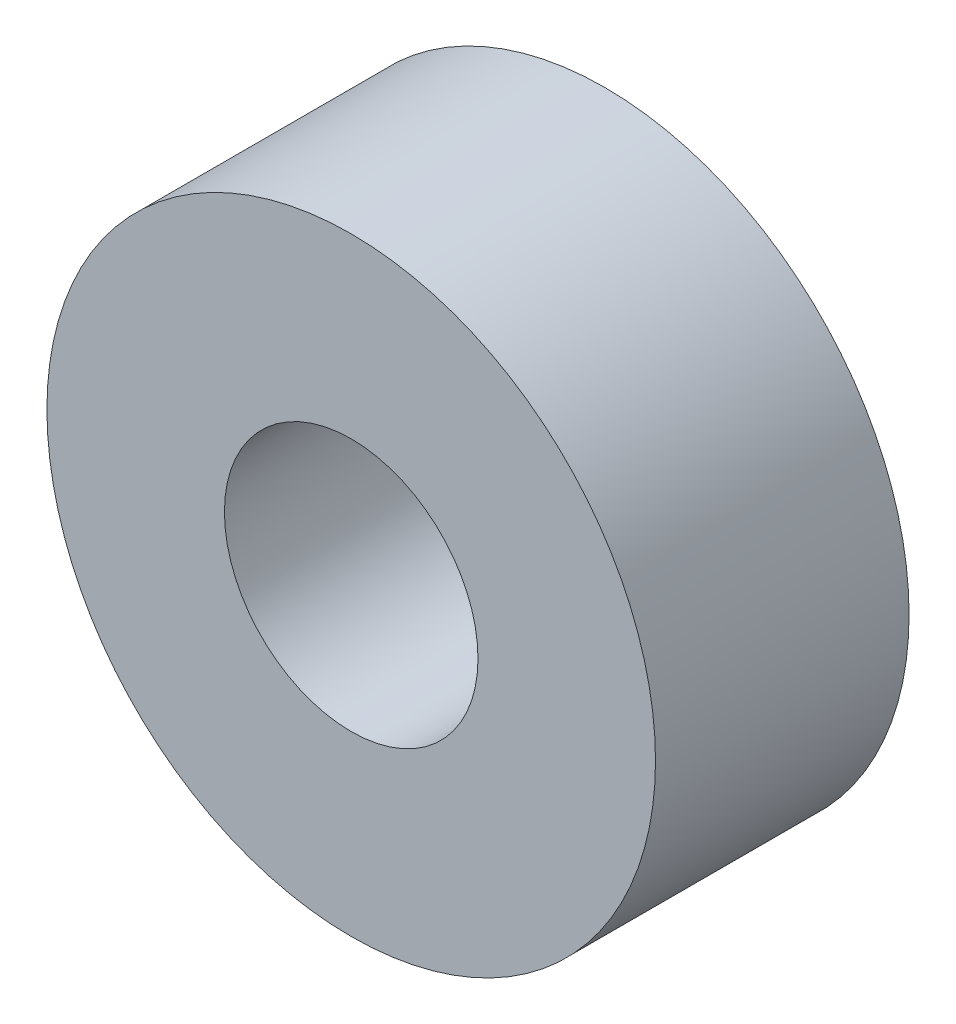
from build123d import *

# Parameters (mm, degrees)
SKETCH_1_R      = 12
SKETCH_1_R_2    = 5
EXTRUDE_1_DEPTH = 5


with BuildPart() as part:
    # 草图1 → 凸台-拉伸1 (new body, symmetric)
    with BuildSketch(Plane.XY):
        Circle(SKETCH_1_R)
        Circle(SKETCH_1_R_2, mode=Mode.SUBTRACT)
    extrude(amount=EXTRUDE_1_DEPTH, both=True)


solid = part.part
